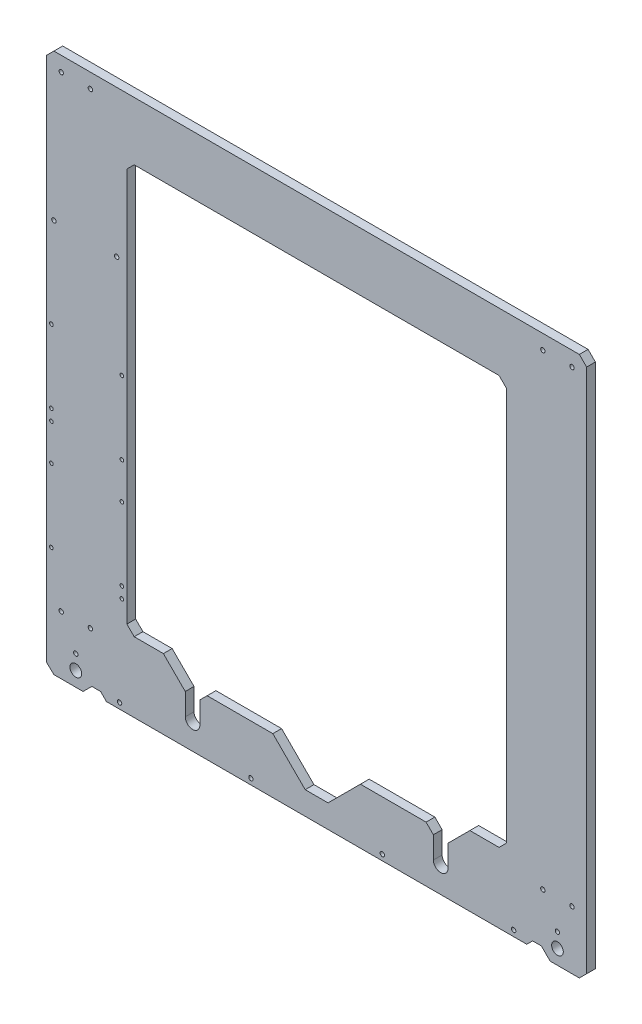
from build123d import *

# Parameters (mm, degrees)
FRAME_R             = 1.25
FRAME_R_2           = 1.5
FRAME_R_3           = 4
BOSS_EXTRUDE1_DEPTH = 6


with BuildPart() as part:
    # FRAME → Boss-Extrude1 (new body)
    with BuildSketch(Plane.XY):
        Polygon((0, 4.808251585), (0, 365), (5, 370), (365, 370), (370, 365), (370, 5), (365, 0), (345, 0), (343, 2), (339, 6), (333, 6), (329, 2), (41, 2), (37, 6), (31, 6), (27, 2), (25, 0), (5, 0), align=None)
        with Locations((3.295108055, 74.610044833)):
            Circle(FRAME_R, mode=Mode.SUBTRACT)
        with Locations((51.555108055, 150.810044833)):
            Circle(FRAME_R, mode=Mode.SUBTRACT)
        with Locations((3.295108055, 157.160044833)):
            Circle(FRAME_R, mode=Mode.SUBTRACT)
        with Locations((3.295108055, 149.540044833)):
            Circle(FRAME_R, mode=Mode.SUBTRACT)
        with Locations((3.295108055, 124.610044833)):
            Circle(FRAME_R, mode=Mode.SUBTRACT)
        with Locations((51.555108055, 125.880044833)):
            Circle(FRAME_R, mode=Mode.SUBTRACT)
        with Locations((51.555108055, 200.810044833)):
            Circle(FRAME_R, mode=Mode.SUBTRACT)
        with Locations((3.295108055, 207.160044833)):
            Circle(FRAME_R, mode=Mode.SUBTRACT)
        with Locations((50, 6)):
            Circle(FRAME_R_2, mode=Mode.SUBTRACT)
        with Locations((320, 6)):
            Circle(FRAME_R_2, mode=Mode.SUBTRACT)
        with Locations((230, 6)):
            Circle(FRAME_R_2, mode=Mode.SUBTRACT)
        with Locations((140, 6)):
            Circle(FRAME_R_2, mode=Mode.SUBTRACT)
        with Locations((20, 10)):
            Circle(FRAME_R_3, mode=Mode.SUBTRACT)
        with Locations((350, 10)):
            Circle(FRAME_R_3, mode=Mode.SUBTRACT)
        with Locations((10, 40)):
            Circle(FRAME_R_2, mode=Mode.SUBTRACT)
        with Locations((30, 40)):
            Circle(FRAME_R_2, mode=Mode.SUBTRACT)
        with Locations((20, 20)):
            Circle(FRAME_R_2, mode=Mode.SUBTRACT)
        with Locations((350, 20)):
            Circle(FRAME_R_2, mode=Mode.SUBTRACT)
        with Locations((340, 40)):
            Circle(FRAME_R_2, mode=Mode.SUBTRACT)
        with Locations((360, 40)):
            Circle(FRAME_R_2, mode=Mode.SUBTRACT)
        with Locations((360, 360)):
            Circle(FRAME_R_2, mode=Mode.SUBTRACT)
        with Locations((340, 360)):
            Circle(FRAME_R_2, mode=Mode.SUBTRACT)
        with Locations((10, 360)):
            Circle(FRAME_R_2, mode=Mode.SUBTRACT)
        with Locations((30, 360)):
            Circle(FRAME_R_2, mode=Mode.SUBTRACT)
        with Locations((51.555108055, 75.880044833)):
            Circle(FRAME_R, mode=Mode.SUBTRACT)
        with Locations((51.555108055, 68.260044833)):
            Circle(FRAME_R, mode=Mode.SUBTRACT)
        with Locations((5, 269.5)):
            Circle(FRAME_R_2, mode=Mode.SUBTRACT)
        with Locations((48, 269.5)):
            Circle(FRAME_R_2, mode=Mode.SUBTRACT)
        with BuildLine():
            Line((95, 20), (95, 35))
            Line((95, 35), (80, 50))
            Line((80, 50), (60, 50))
            Line((60, 50), (55, 55))
            Line((55, 55), (55, 325))
            Line((55, 325), (60, 330))
            Line((60, 330), (310, 330))
            Line((310, 330), (315, 325))
            Line((315, 325), (315, 55))
            Line((315, 55), (310, 50))
            Line((310, 50), (290, 50))
            Line((290, 50), (275, 35))
            Line((275, 35), (275, 20))
            ThreePointArc((275, 20), (270, 15), (265, 20))
            Line((265, 20), (265, 35))
            Line((265, 35), (260, 40))
            Line((260, 40), (215, 40))
            Line((215, 40), (192.824919816, 17.824919816))
            Line((192.824919816, 17.824919816), (177.175080184, 17.824919816))
            Line((177.175080184, 17.824919816), (155, 40))
            Line((155, 40), (110, 40))
            Line((110, 40), (105, 35))
            Line((105, 35), (105, 20))
            ThreePointArc((105, 20), (100, 15), (95, 20))
        make_face(mode=Mode.SUBTRACT)
    extrude(amount=BOSS_EXTRUDE1_DEPTH)


solid = part.part
